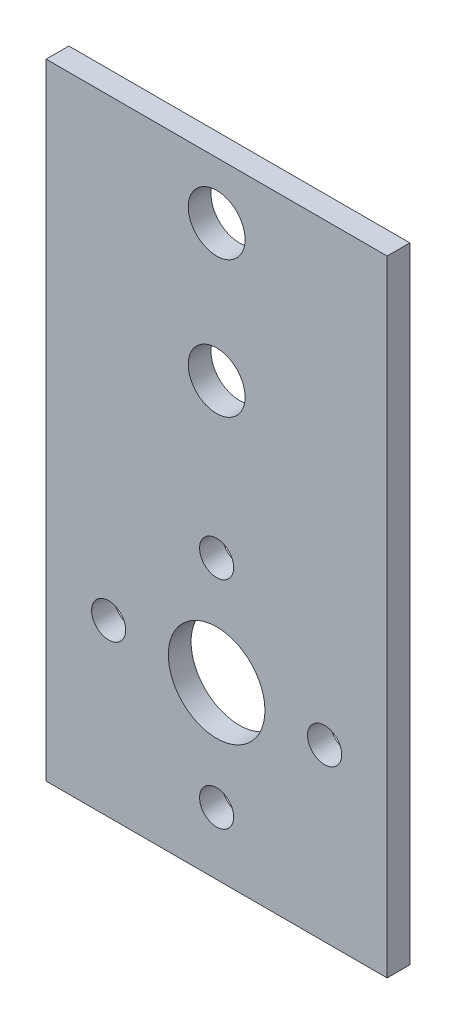
from build123d import *

# Parameters (mm, degrees)
SKETCH1_W           = 30
SKETCH1_H           = 30
SKETCH1_R           = 4.25
SKETCH1_R_2         = 1.5
BOSS_EXTRUDE1_DEPTH = 2
SKETCH2_W           = 30
SKETCH2_H           = 2
BOSS_EXTRUDE2_DEPTH = 25
SKETCH3_R           = 2.5
CUT_EXTRUDE1_DEPTH  = 2


with BuildPart() as part:
    # Sketch1 → Boss-Extrude1 (new body)
    with BuildSketch(Plane.XY):
        Rectangle(SKETCH1_W, SKETCH1_H)
        Circle(SKETCH1_R, mode=Mode.SUBTRACT)
        with Locations((0, 9.5)):
            Circle(SKETCH1_R_2, mode=Mode.SUBTRACT)
        with Locations((9.5, 0)):
            Circle(SKETCH1_R_2, mode=Mode.SUBTRACT)
        with Locations((0, -9.5)):
            Circle(SKETCH1_R_2, mode=Mode.SUBTRACT)
        with Locations((-9.5, 0)):
            Circle(SKETCH1_R_2, mode=Mode.SUBTRACT)
    extrude(amount=BOSS_EXTRUDE1_DEPTH)

    # Sketch2 → Boss-Extrude2 (add)
    with BuildSketch(Plane(origin=(0, 15, 0), x_dir=(1, 0, 0), z_dir=(0, 1, 0))):
        with Locations((0, -1)):
            Rectangle(SKETCH2_W, SKETCH2_H)
    extrude(amount=BOSS_EXTRUDE2_DEPTH)

    # Sketch3 → Cut-Extrude1 (cut)
    with BuildSketch(Plane.XY.offset(2)):
        with Locations((0, 23)):
            Circle(SKETCH3_R)
        with Locations((0, 35)):
            Circle(SKETCH3_R)
    extrude(amount=-CUT_EXTRUDE1_DEPTH, mode=Mode.SUBTRACT)


solid = part.part
